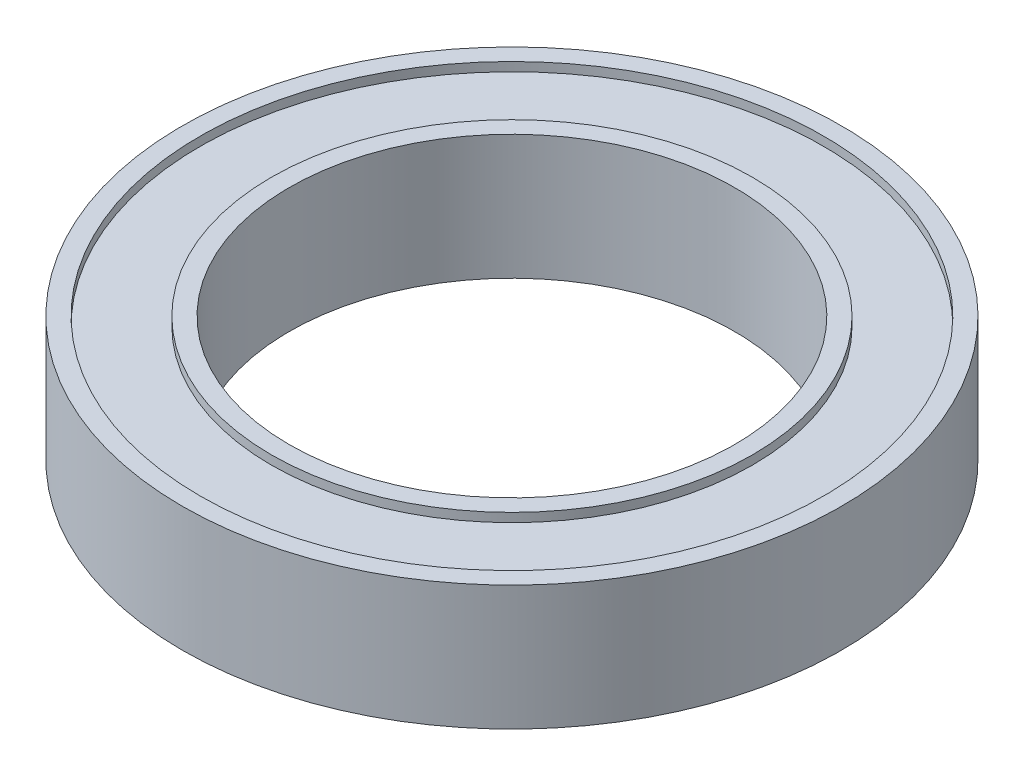
from build123d import *

# Parameters (mm, degrees)
EXTRUDE_1_DEPTH        = 3.5
EXTRUDE_1_DEPTH_BACK   = 3.5
SKETCH_1_R             = 13.5
SKETCH_1_R_2           = 12.5
EXTRUDE_1_2_DEPTH      = 3.5
EXTRUDE_1_2_DEPTH_BACK = 3.5
SKETCH_1_R_3           = 18.5
SKETCH_1_R_4           = 17.5
EXTRUDE_2_DEPTH        = 3
EXTRUDE_2_DEPTH_BACK   = 3
SKETCH_2_R             = 17.5
SKETCH_2_R_2           = 13.5


with BuildPart() as part:
    # 草图1 → 凸台-拉伸1 (new, two sides: drawn at the far end of the back side and taken through both)
    with BuildSketch(Plane(origin=(0, 0, 0), x_dir=(1, 0, 0), z_dir=(0, 1, 0)).offset(-EXTRUDE_1_DEPTH_BACK)):
        Circle(SKETCH_1_R)
        Circle(SKETCH_1_R_2, mode=Mode.SUBTRACT)
    extrude(amount=EXTRUDE_1_DEPTH + EXTRUDE_1_DEPTH_BACK)



with BuildPart() as body_2:
    # 草图1 → Extrude 1 2 (new, two sides: drawn at the far end of the back side and taken through both)
    with BuildSketch(Plane(origin=(0, 0, 0), x_dir=(1, 0, 0), z_dir=(0, 1, 0)).offset(-EXTRUDE_1_2_DEPTH_BACK)):
        Circle(SKETCH_1_R_3)
        Circle(SKETCH_1_R_4, mode=Mode.SUBTRACT)
    extrude(amount=EXTRUDE_1_2_DEPTH + EXTRUDE_1_2_DEPTH_BACK)


with BuildPart() as part_1:
    add(part.part)

    add(body_2.part)  # 凸台-拉伸2 merges body 2
    # 草图2 → 凸台-拉伸2 (add, two sides: drawn at the far end of the back side and taken through both)
    with BuildSketch(Plane(origin=(0, 0, 0), x_dir=(1, 0, 0), z_dir=(0, 1, 0)).offset(-EXTRUDE_2_DEPTH_BACK)):
        Circle(SKETCH_2_R)
        Circle(SKETCH_2_R_2, mode=Mode.SUBTRACT)
    extrude(amount=EXTRUDE_2_DEPTH + EXTRUDE_2_DEPTH_BACK)


solid = part_1.part
